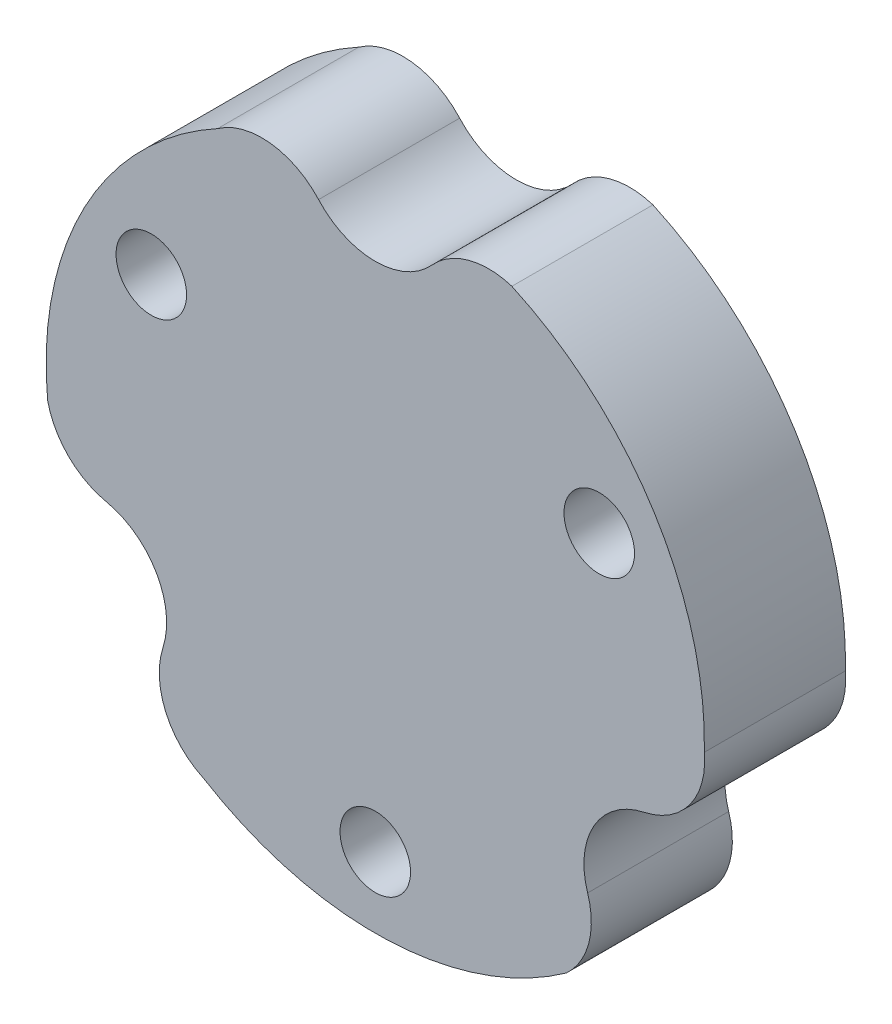
from build123d import *

# Parameters (mm, degrees)
ESQUISSE1_R        = 1.5
BOSS_EXTRU_2_DEPTH = 6


with BuildPart() as part:
    # Esquisse1 → Boss.-Extru.2 (new body)
    with BuildSketch(Plane.XY):
        with BuildLine():
            ThreePointArc((-2.411034891, 11.820685714), (0, 10.75), (2.411034891, 11.820685714))
            ThreePointArc((2.411034891, 11.820685714), (3.975330286, 12.779130538), (5.80943088, 12.737759334))
            ThreePointArc((5.80943088, 12.737759334), (11.865562564, 7.430237213), (13.995977593, -0.335575935))
            ThreePointArc((13.995977593, -0.335575935), (13.382779595, -2.564868949), (11.442531564, -3.822325392))
            ThreePointArc((11.442531564, -3.822325392), (9.309773091, -5.375), (9.031496673, -7.998360322))
            ThreePointArc((9.031496673, -7.998360322), (9.079386541, -9.832302285), (8.126507731, -11.399994391))
            ThreePointArc((8.126507731, -11.399994391), (0.5019929, -13.990997217), (-7.288606081, -11.953084179))
            ThreePointArc((-7.288606081, -11.953084179), (-8.912631465, -10.307392628), (-9.031496673, -7.998360322))
            ThreePointArc((-9.031496673, -7.998360322), (-9.309773091, -5.375), (-11.442531564, -3.822325392))
            ThreePointArc((-11.442531564, -3.822325392), (-13.054716827, -2.946828253), (-13.935938611, -1.337764944))
            ThreePointArc((-13.935938611, -1.337764944), (-12.367555464, 6.560760004), (-6.707371512, 12.288660114))
            ThreePointArc((-6.707371512, 12.288660114), (-4.47014813, 12.872261577), (-2.411034891, 11.820685714))
        make_face()
        with Locations((9.526279442, 5.5)):
            Circle(ESQUISSE1_R, mode=Mode.SUBTRACT)
        with Locations((0, -11)):
            Circle(ESQUISSE1_R, mode=Mode.SUBTRACT)
        with Locations((-9.526279442, 5.5)):
            Circle(ESQUISSE1_R, mode=Mode.SUBTRACT)
    extrude(amount=BOSS_EXTRU_2_DEPTH)


solid = part.part
